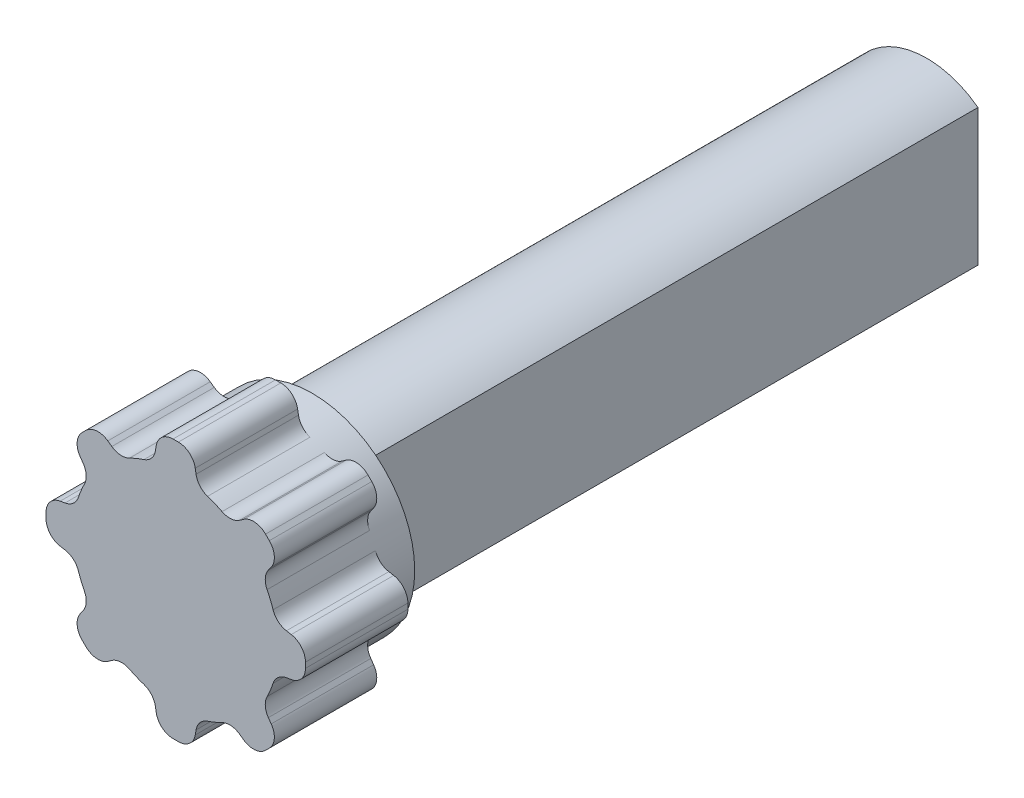
from build123d import *

# Parameters (mm, degrees)
BOSS_EXTRUDE1_DEPTH      = 25.4
SKETCH2_R                = 3.81
BOSS_EXTRUDE2_DEPTH      = 2.54
BOSS_EXTRUDE3_DEPTH      = 3.81
FILLET1_R                = 0.635
CIRPATTERN1_COUNT        = 8
FILLET1_OF_CIRPATTERN1_R = 0.635


with BuildPart() as part:
    # Sketch1 → Boss-Extrude1 (new body)
    with BuildSketch(Plane.XY):
        with BuildLine():
            Line((1.905, 2.54), (1.905, -2.54))
            ThreePointArc((1.905, -2.54), (-3.175, 0), (1.905, 2.54))
        make_face()
    extrude(amount=-BOSS_EXTRUDE1_DEPTH)

    # Sketch2 → Boss-Extrude2 (add, symmetric)
    with BuildSketch(Plane.XY):
        Circle(SKETCH2_R)
    extrude(amount=BOSS_EXTRUDE2_DEPTH, both=True)

    # Sketch4 → Boss-Extrude3 (add)
    with BuildSketch(Plane.XY.offset(2.54)):
        Polygon((-0.635, 4.826), (0.635, 4.826), (0.824634929, 3.719687787), (-0.824634929, 3.719687787), align=None)
    boss_extrude3 = extrude(amount=-BOSS_EXTRUDE3_DEPTH)

    # Fillet1
    fillet1_edges = [part.edges().sort_by_distance(p)[0] for p in [
        (0.635, 4.826, 0.635),
        (0.824634929, 3.719687787, 0.635),
        (-0.824634929, 3.719687787, 0.635),
        (-0.635, 4.826, 0.635),
    ]]
    fillet(fillet1_edges, radius=FILLET1_R)

    # CirPattern1: Boss-Extrude3 ×8 about axis
    cirpattern1_axis = Axis((0, 0, 0), (0, 0, 1))
    for i in range(1, CIRPATTERN1_COUNT):
        add(boss_extrude3.rotate(cirpattern1_axis, i * 360 / CIRPATTERN1_COUNT))

    # Fillet1 of CirPattern1
    fillet1_of_cirpattern1_edges = [part.edges().sort_by_distance(p)[0] for p in [
        (-2.96348452, 3.861510132, 0.635),
        (-2.047111508, 3.213321409, 0.635),
        (-3.213321409, 2.047111508, 0.635),
        (-3.861510132, 2.96348452, 0.635),
        (-4.826, 0.635, 0.635),
        (-3.719687787, 0.824634929, 0.635),
        (-3.719687787, -0.824634929, 0.635),
        (-4.826, -0.635, 0.635),
        (-3.861510132, -2.96348452, 0.635),
        (-3.213321409, -2.047111508, 0.635),
        (-2.047111508, -3.213321409, 0.635),
        (-2.96348452, -3.861510132, 0.635),
        (-0.635, -4.826, 0.635),
        (-0.824634929, -3.719687787, 0.635),
        (0.824634929, -3.719687787, 0.635),
        (0.635, -4.826, 0.635),
        (2.96348452, -3.861510132, 0.635),
        (2.047111508, -3.213321409, 0.635),
        (3.213321409, -2.047111508, 0.635),
        (3.861510132, -2.96348452, 0.635),
        (4.826, -0.635, 0.635),
        (3.719687787, -0.824634929, 0.635),
        (3.719687787, 0.824634929, 0.635),
        (4.826, 0.635, 0.635),
        (3.861510132, 2.96348452, 0.635),
        (3.213321409, 2.047111508, 0.635),
        (2.047111508, 3.213321409, 0.635),
        (2.96348452, 3.861510132, 0.635),
    ]]
    fillet(fillet1_of_cirpattern1_edges, radius=FILLET1_OF_CIRPATTERN1_R)


solid = part.part
